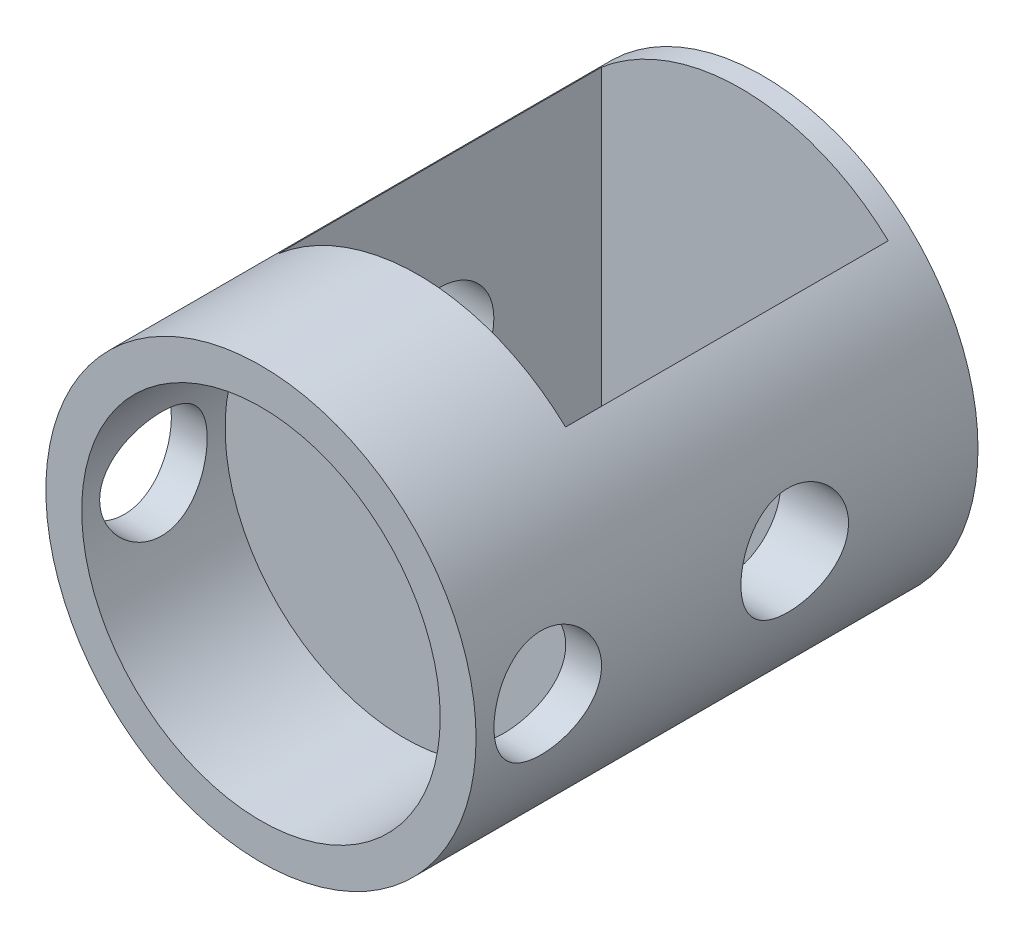
from build123d import *

# Parameters (mm, degrees)
SKETCH2_R               = 6
BOSS_EXTRUDE1_DEPTH     = 14
SKETCH3_R               = 5
CUT_EXTRUDE1_DEPTH      = 4
SKETCH4_R               = 1.5
CUT_EXTRUDE2_DEPTH      = 7
CUT_EXTRUDE2_DEPTH_BACK = 7
SKETCH7_W               = 8
SKETCH7_H               = 9
CUT_EXTRUDE5_DEPTH      = 7.0000001
CUT_EXTRUDE5_DEPTH_BACK = 7.0000001
SKETCH8_R               = 1.5
CUT_EXTRUDE6_DEPTH      = 7.0000001
CUT_EXTRUDE6_DEPTH_BACK = 7.0000001


with BuildPart() as part:
    # Sketch2 → Boss-Extrude1 (new body)
    with BuildSketch(Plane.XY):
        Circle(SKETCH2_R)
    extrude(amount=BOSS_EXTRUDE1_DEPTH)

    # Sketch3 → Cut-Extrude1 (cut)
    with BuildSketch(Plane.XY.offset(14)):
        Circle(SKETCH3_R)
    extrude(amount=-CUT_EXTRUDE1_DEPTH, mode=Mode.SUBTRACT)

    # Sketch4 → Cut-Extrude2 (cut, two sides)
    with BuildSketch(Plane(origin=(0, 0, 0), x_dir=(0, 0, -1), z_dir=(1, 0, 0))) as cut_extrude2_sk:
        with Locations((-12, 0)):
            Circle(SKETCH4_R)
    extrude(amount=CUT_EXTRUDE2_DEPTH, mode=Mode.SUBTRACT)
    extrude(cut_extrude2_sk.sketch, amount=-CUT_EXTRUDE2_DEPTH_BACK, mode=Mode.SUBTRACT)

    # Sketch7 → Cut-Extrude5 (cut, two sides)
    with BuildSketch(Plane(origin=(0, 0, 0), x_dir=(1, 0, 0), z_dir=(0, 1, 0))) as cut_extrude5_sk:
        with Locations((0.10757358, -5.111243205)):
            Rectangle(SKETCH7_W, SKETCH7_H)
    extrude(amount=CUT_EXTRUDE5_DEPTH, mode=Mode.SUBTRACT)
    extrude(cut_extrude5_sk.sketch, amount=-CUT_EXTRUDE5_DEPTH_BACK, mode=Mode.SUBTRACT)

    # Sketch8 → Cut-Extrude6 (cut, two sides)
    with BuildSketch(Plane(origin=(0, 0, 0), x_dir=(0, 0, -1), z_dir=(1, 0, 0))) as cut_extrude6_sk:
        with Locations((-5.111243205, 0)):
            Circle(SKETCH8_R)
    extrude(amount=CUT_EXTRUDE6_DEPTH, mode=Mode.SUBTRACT)
    extrude(cut_extrude6_sk.sketch, amount=-CUT_EXTRUDE6_DEPTH_BACK, mode=Mode.SUBTRACT)


solid = part.part
